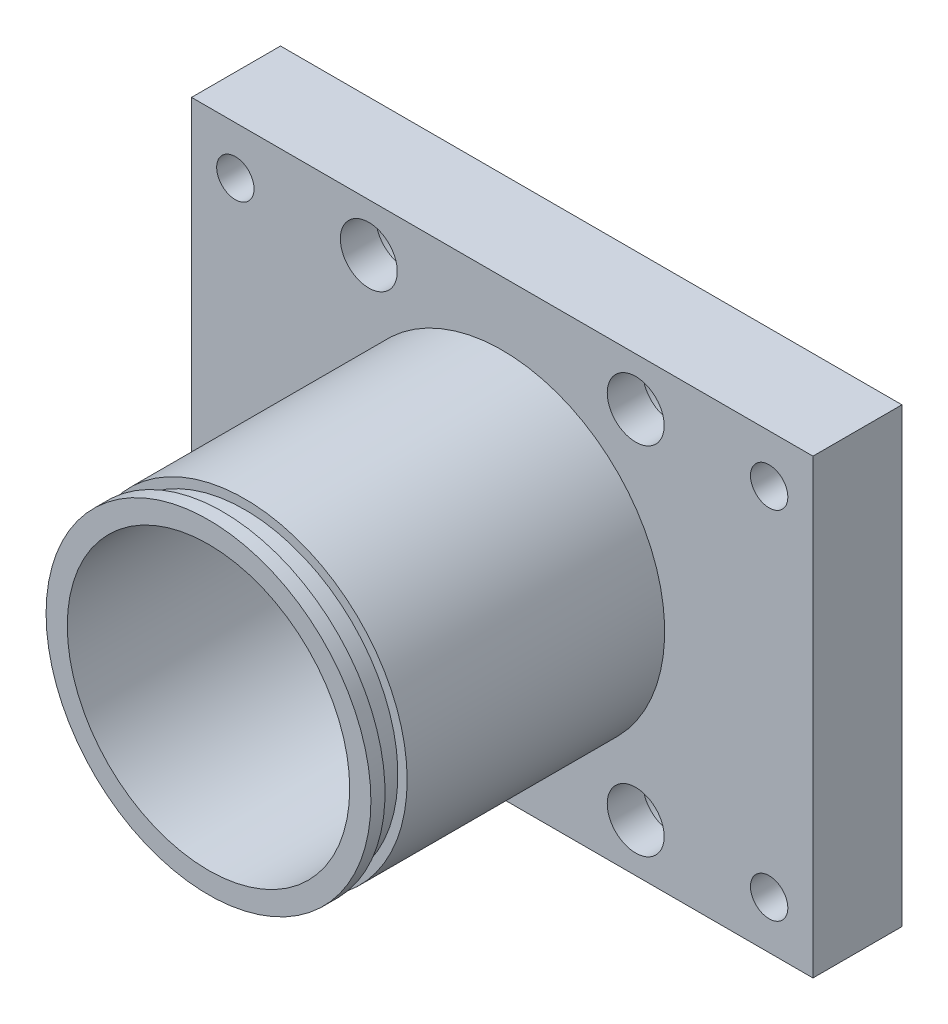
from build123d import *

# Parameters (mm, degrees)
SKETCH1_W                      = 69.85
SKETCH1_H                      = 50.8
BOSS_EXTRUDE1_DEPTH            = 10
SKETCH2_R                      = 15.875
CUT_EXTRUDE1_DEPTH             = 11
M5X0_8_TAPPED_HOLE1_D          = 4.2
CBORE_FOR_M6_SHCS1_D           = 6.4
CBORE_FOR_M6_SHCS1_CBORE_D     = 10.1
CBORE_FOR_M6_SHCS1_CBORE_DEPTH = 6
MIRROR2_COPY_1_D               = 4.2
MIRROR2_COPY_2_D               = 6.4
MIRROR2_COPY_2_CBORE_D         = 10.1
MIRROR2_COPY_2_CBORE_DEPTH     = 6
SKETCH7_R                      = 18.25625
SKETCH7_R_2                    = 15.875
BOSS_EXTRUDE2_DEPTH            = 33.02
SKETCH8_R                      = 18.85315
SKETCH8_R_2                    = 16.66875
CUT_EXTRUDE2_DEPTH             = 1.3208
SKETCH9_W                      = 2.4892
SKETCH9_H                      = 1.2954


with BuildPart() as part:
    # Sketch1 → Boss-Extrude1 (new body)
    with BuildSketch(Plane.XY):
        Rectangle(SKETCH1_W, SKETCH1_H)
    extrude(amount=BOSS_EXTRUDE1_DEPTH)

    # Sketch2 → Cut-Extrude1 (cut, through all)
    with BuildSketch(Plane.XY.offset(10)):
        Circle(SKETCH2_R)
    extrude(amount=-CUT_EXTRUDE1_DEPTH, mode=Mode.SUBTRACT)

    # M5x0.8 Tapped Hole1 (through all)
    with Locations(Plane.XY.offset(10)):
        with Locations((30, 19.999999878)):
            m5x0_8_tapped_hole1 = Hole(M5X0_8_TAPPED_HOLE1_D / 2)

    # CBORE for M6 SHCS1 (through all)
    with Locations(Plane(origin=(0, 0, 0), x_dir=(-1, 0, 0), z_dir=(0, 0, -1))):
        with Locations((-15, 20)):
            cbore_for_m6_shcs1 = CounterBoreHole(CBORE_FOR_M6_SHCS1_D / 2, CBORE_FOR_M6_SHCS1_CBORE_D / 2, CBORE_FOR_M6_SHCS1_CBORE_DEPTH)

    # Mirror1: M5x0.8 Tapped Hole1, CBORE for M6 SHCS1 across plane
    add(m5x0_8_tapped_hole1.mirror(Plane.ZX), mode=Mode.SUBTRACT)
    add(cbore_for_m6_shcs1.mirror(Plane.ZX), mode=Mode.SUBTRACT)

    # Mirror2: M5x0.8 Tapped Hole1, CBORE for M6 SHCS1 across plane
    add(m5x0_8_tapped_hole1.mirror(Plane(origin=(0, 0, 0), x_dir=(0, 0, 1), z_dir=(1, 0, 0))), mode=Mode.SUBTRACT)
    add(cbore_for_m6_shcs1.mirror(Plane(origin=(0, 0, 0), x_dir=(0, 0, 1), z_dir=(1, 0, 0))), mode=Mode.SUBTRACT)

    # Mirror2 copy 1 (through all)
    with Locations(Plane(origin=(0, 0, 10), x_dir=(-1, 0, 0), z_dir=(0, 0, 1))):
        with Locations((30, 19.999999878)):
            Hole(MIRROR2_COPY_1_D / 2)

    # Mirror2 copy 2 (through all)
    with Locations(Plane(origin=(0, 0, 0), x_dir=(1, 0, 0), z_dir=(0, 0, -1))):
        with Locations((-15, 20)):
            CounterBoreHole(MIRROR2_COPY_2_D / 2, MIRROR2_COPY_2_CBORE_D / 2, MIRROR2_COPY_2_CBORE_DEPTH)

    # Sketch7 → Boss-Extrude2 (add)
    with BuildSketch(Plane.XY.offset(10)):
        Circle(SKETCH7_R)
        Circle(SKETCH7_R_2, mode=Mode.SUBTRACT)
    extrude(amount=BOSS_EXTRUDE2_DEPTH)

    # Sketch8 → Cut-Extrude2 (cut)
    with BuildSketch(Plane(origin=(0, 0, 0), x_dir=(-1, 0, 0), z_dir=(0, 0, -1))):
        Circle(SKETCH8_R)
        Circle(SKETCH8_R_2, mode=Mode.SUBTRACT)
    extrude(amount=-CUT_EXTRUDE2_DEPTH, mode=Mode.SUBTRACT)

    # Sketch9 → Cut-Revolve1 (revolve, cut)
    with BuildSketch(Plane(origin=(0, 0, 0), x_dir=(0, 0, -1), z_dir=(1, 0, 0))):
        with Locations((-40.1879, -17.85874)):
            Rectangle(SKETCH9_W, SKETCH9_H)
    revolve(axis=Axis((0, 0, -4.391211434), (0, 0, 1)), mode=Mode.SUBTRACT)


solid = part.part
